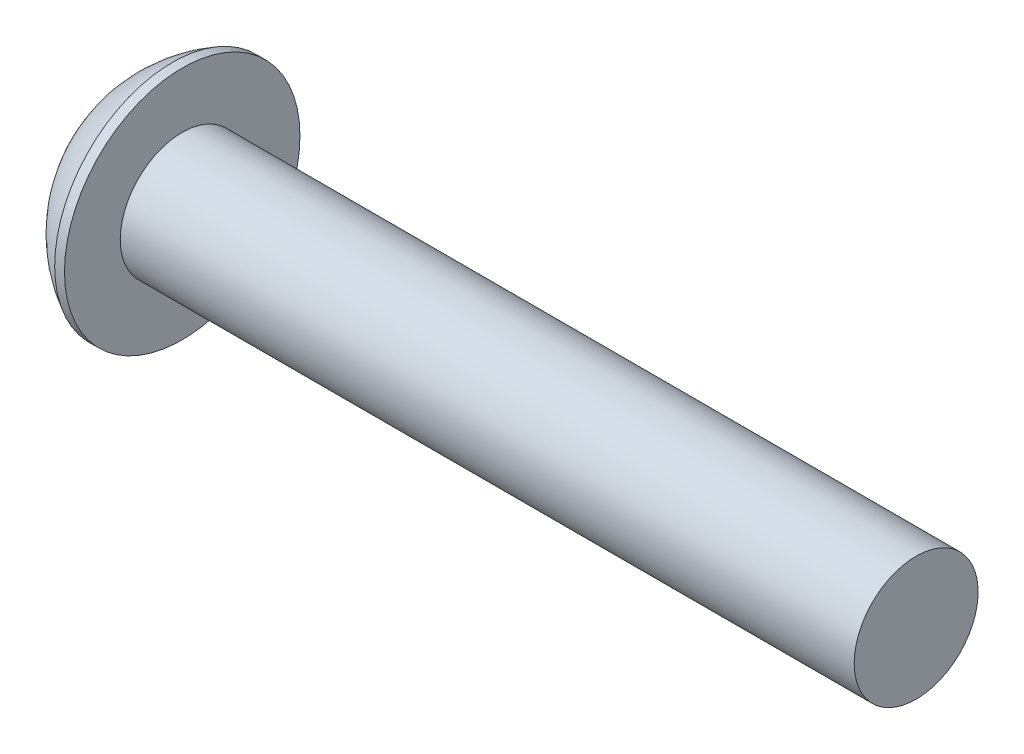
from build123d import *

# Parameters (mm, degrees)
CUT_EXTRUDE1_DEPTH = 1.8288


with BuildPart() as part:
    # Sketch1 → Revolve1 (revolve)
    with BuildSketch(Plane.XY):
        with BuildLine():
            Line((0, 0), (29.3116, 0))
            Line((29.3116, 0), (29.3116, 2.413))
            Line((29.3116, 2.413), (0.7366, 2.413))
            Line((0.7366, 2.413), (0.7366, 4.5847))
            Line((0.7366, 4.5847), (0.3556, 4.5847))
            ThreePointArc((0.3556, 4.5847), (-0.901703741, 3.66491926), (-1.8288, 2.413))
            Line((-1.8288, 2.413), (-1.8288, 1.8288))
            Line((-1.8288, 1.8288), (0, 0))
        make_face()
    revolve(axis=Axis((0, 0, 0), (1, 0, 0)))

    # Sketch2 → Cut-Extrude1 (cut)
    with BuildSketch(Plane.ZY.offset(1.8288)):
        Polygon((1.833087105, 0), (0.916543552, 1.5875), (-0.916543552, 1.5875), (-1.833087105, 0), (-0.916543552, -1.5875), (0.916543552, -1.5875), align=None)
    extrude(amount=-CUT_EXTRUDE1_DEPTH, mode=Mode.SUBTRACT)


solid = part.part
